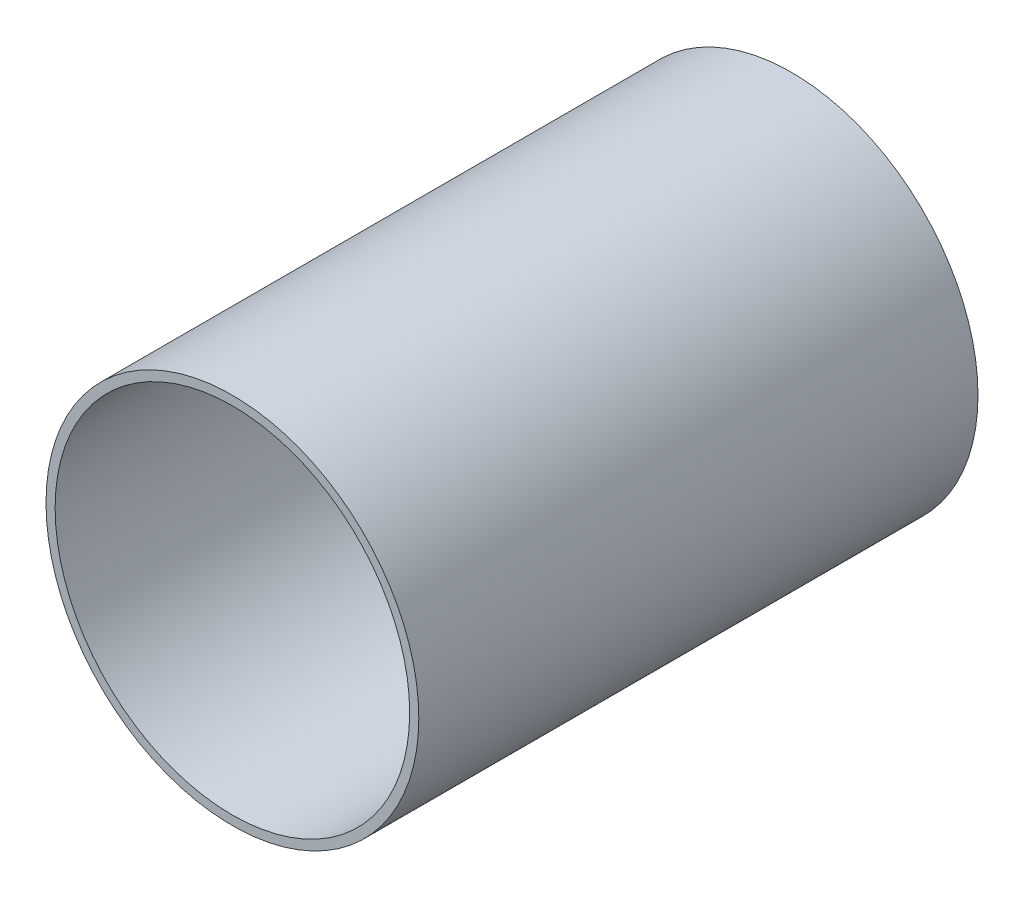
from build123d import *

# Parameters (mm, degrees)
SKETCH2_R           = 25.4
SKETCH2_R_2         = 24.1554
BOSS_EXTRUDE1_DEPTH = 76.2


with BuildPart() as part:
    # Sketch2 → Boss-Extrude1 (new body)
    with BuildSketch(Plane.XY):
        Circle(SKETCH2_R)
        Circle(SKETCH2_R_2, mode=Mode.SUBTRACT)
    extrude(amount=BOSS_EXTRUDE1_DEPTH)


solid = part.part
